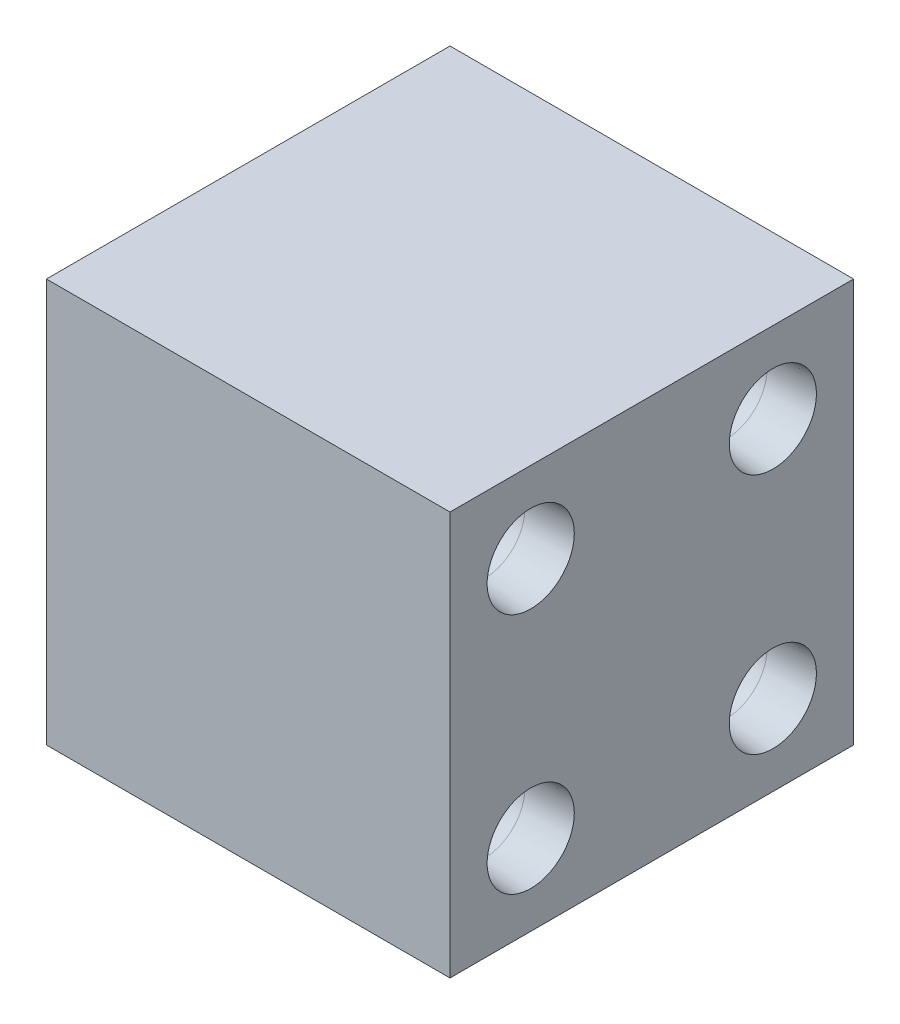
from build123d import *

# Parameters (mm, degrees)
SKETCH2_W            = 25
SKETCH2_H            = 25
BOSS_EXTRUDE1_DEPTH  = 25
LPATTERN1_COUNT      = 2
LPATTERN1_PITCH      = 15
LPATTERN1_COUNT_DIR2 = 2
LPATTERN1_PITCH_DIR2 = 15


with BuildPart() as part:
    # Sketch2 → Boss-Extrude1 (new body)
    with BuildSketch(Plane(origin=(0, 0, 0), x_dir=(1, 0, 0), z_dir=(0, 1, 0))):
        Rectangle(SKETCH2_W, SKETCH2_H)
    extrude(amount=BOSS_EXTRUDE1_DEPTH)

    # Sketch4 → CSK for M3 Oval Head Machine Screw1 (revolve, cut)
    with BuildSketch(Plane(origin=(-12.5, 20, -7.5), x_dir=(0, 0, 1), z_dir=(0, 1, 0))):
        Polygon((0, 0), (0, 11.502151548), (2.5, 10), (2.5, 2.860133251), (2.7, 0), align=None)
    csk_for_m3_oval_head_machine_screw1 = revolve(axis=Axis((-18.85, 20, -7.5), (1, 0, 0)), mode=Mode.SUBTRACT)

    # LPattern1: CSK for M3 Oval Head Machine Screw1 2 × 2
    with Locations(*[(0, -i * LPATTERN1_PITCH, j * LPATTERN1_PITCH_DIR2) for i in range(LPATTERN1_COUNT) for j in range(LPATTERN1_COUNT_DIR2) if (i, j) != (0, 0)]):
        add(csk_for_m3_oval_head_machine_screw1, mode=Mode.SUBTRACT)

    # Mirror1: CSK for M3 Oval Head Machine Screw1 across plane
    add(csk_for_m3_oval_head_machine_screw1.mirror(Plane(origin=(0, 0, 0), x_dir=(0, 0, 1), z_dir=(1, 0, 0))), mode=Mode.SUBTRACT)

    # Mirror1 copy 1 sketch → Mirror1 copy 1 (revolve, cut)
    with BuildSketch(Plane(origin=(12.5, 20, 7.5), x_dir=(0, 0, 1), z_dir=(0, 1, 0))):
        Polygon((0, 0), (0, -11.502151548), (2.5, -10), (2.5, -2.860133251), (2.7, 0), align=None)
    revolve(axis=Axis((18.85, 20, 7.5), (1, 0, 0)), mode=Mode.SUBTRACT)

    # Mirror1 copy 2 sketch → Mirror1 copy 2 (revolve, cut)
    with BuildSketch(Plane(origin=(12.5, 5, -7.5), x_dir=(0, 0, 1), z_dir=(0, 1, 0))):
        Polygon((0, 0), (0, -11.502151548), (2.5, -10), (2.5, -2.860133251), (2.7, 0), align=None)
    revolve(axis=Axis((18.85, 5, -7.5), (1, 0, 0)), mode=Mode.SUBTRACT)

    # Mirror1 copy 3 sketch → Mirror1 copy 3 (revolve, cut)
    with BuildSketch(Plane(origin=(12.5, 5, 7.5), x_dir=(0, 0, 1), z_dir=(0, 1, 0))):
        Polygon((0, 0), (0, -11.502151548), (2.5, -10), (2.5, -2.860133251), (2.7, 0), align=None)
    revolve(axis=Axis((18.85, 5, 7.5), (1, 0, 0)), mode=Mode.SUBTRACT)


solid = part.part
